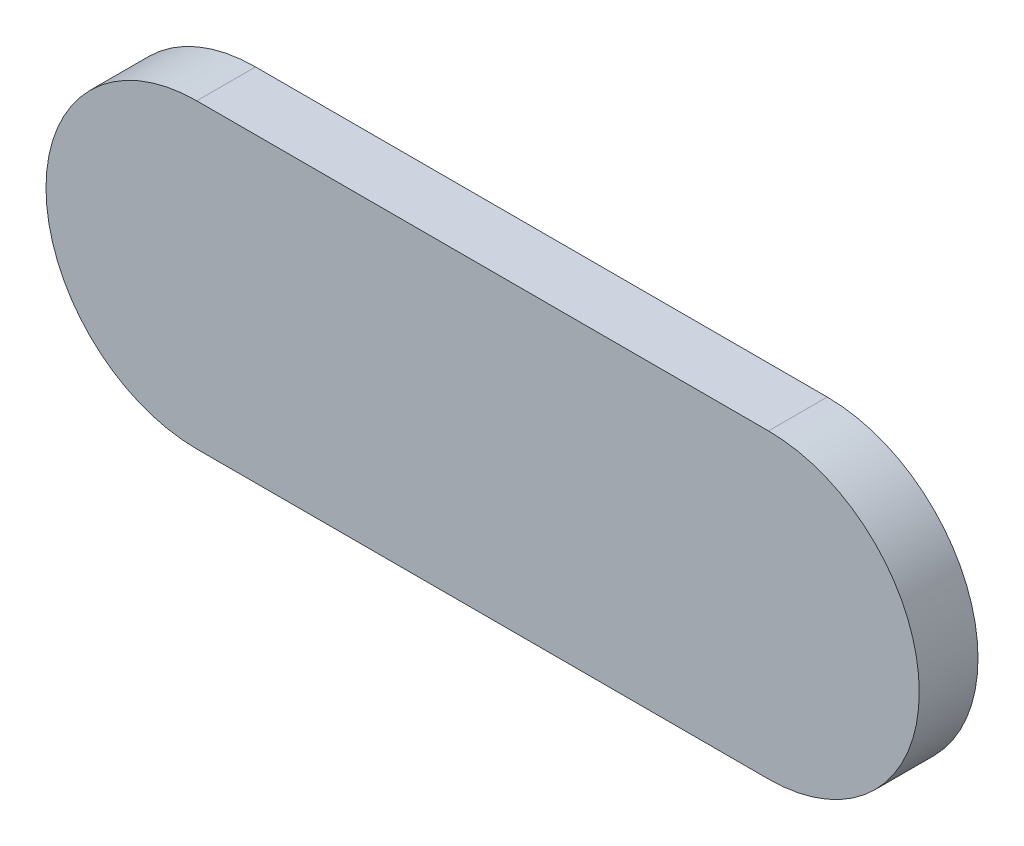
from build123d import *

# Parameters (mm, degrees)
EXTRUDE_1_DEPTH = 1.5
EXTRUDE_2_DEPTH = 0.5
SKETCH_3_R      = 0.75
EXTRUDE_3_DEPTH = 0.2


with BuildPart() as part:
    # 草图1 → 凸台-拉伸1 (new body)
    with BuildSketch(Plane.XY):
        with BuildLine():
            Line((7.3, 3.85), (-7.3, 3.85))
            ThreePointArc((-7.3, 3.85), (-11.15, 0), (-7.3, -3.85))
            Line((-7.3, -3.85), (7.3, -3.85))
            ThreePointArc((7.3, -3.85), (11.15, 0), (7.3, 3.85))
        make_face()
    extrude(amount=EXTRUDE_1_DEPTH)

    # 草图2 → 凸台-拉伸2 (add)
    with BuildSketch(Plane(origin=(0, 0, 0), x_dir=(-1, 0, 0), z_dir=(0, 0, -1))):
        with BuildLine():
            Line((-7.35, 2.3), (7.35, 2.3))
            ThreePointArc((7.35, 2.3), (9.65, 0), (7.35, -2.3))
            Line((7.35, -2.3), (-7.35, -2.3))
            ThreePointArc((-7.35, -2.3), (-9.65, 0), (-7.35, 2.3))
        make_face()
    extrude(amount=EXTRUDE_2_DEPTH)

    # 草图3 → 凸台-拉伸3 (add)
    with BuildSketch(Plane(origin=(0, 0, -0.5), x_dir=(-1, 0, 0), z_dir=(0, 0, -1))):
        with Locations((1.27, 0)):
            Circle(SKETCH_3_R)
        with Locations((3.81, 0)):
            Circle(SKETCH_3_R)
        with Locations((-3.81, 0)):
            Circle(SKETCH_3_R)
        with Locations((-1.27, 0)):
            Circle(SKETCH_3_R)
    extrude(amount=EXTRUDE_3_DEPTH)


solid = part.part
